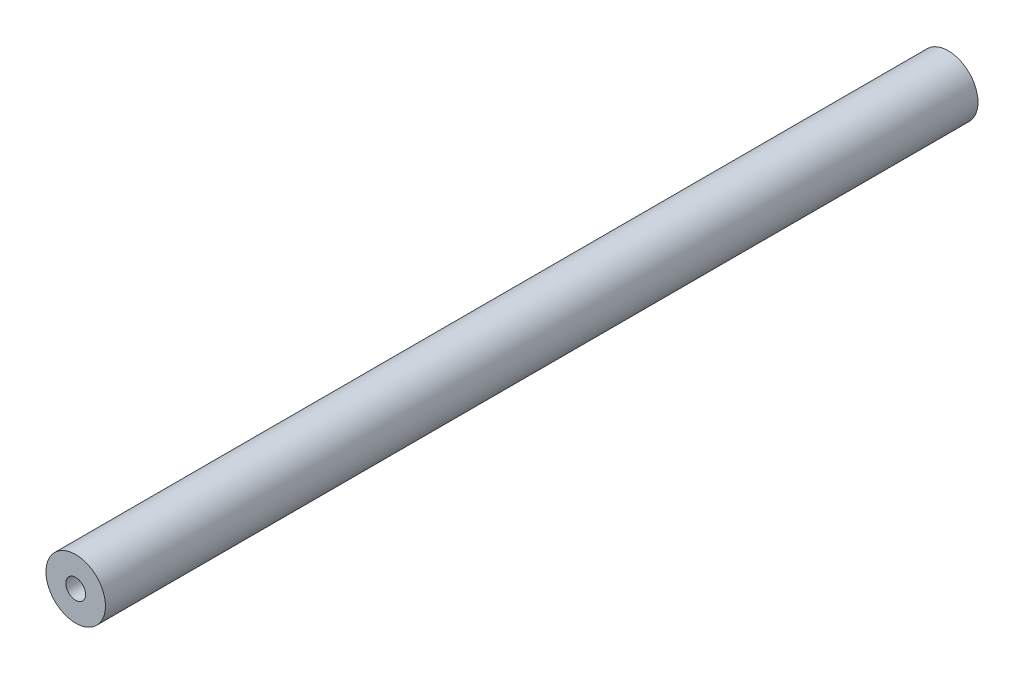
from build123d import *

# Parameters (mm, degrees)
SKETCH1_R           = 4.7625
SKETCH1_R_2         = 1.5875
BOSS_EXTRUDE1_DEPTH = 139.7


with BuildPart() as part:
    # Sketch1 → Boss-Extrude1 (new body)
    with BuildSketch(Plane.XY):
        Circle(SKETCH1_R)
        Circle(SKETCH1_R_2, mode=Mode.SUBTRACT)
    extrude(amount=BOSS_EXTRUDE1_DEPTH)


solid = part.part
